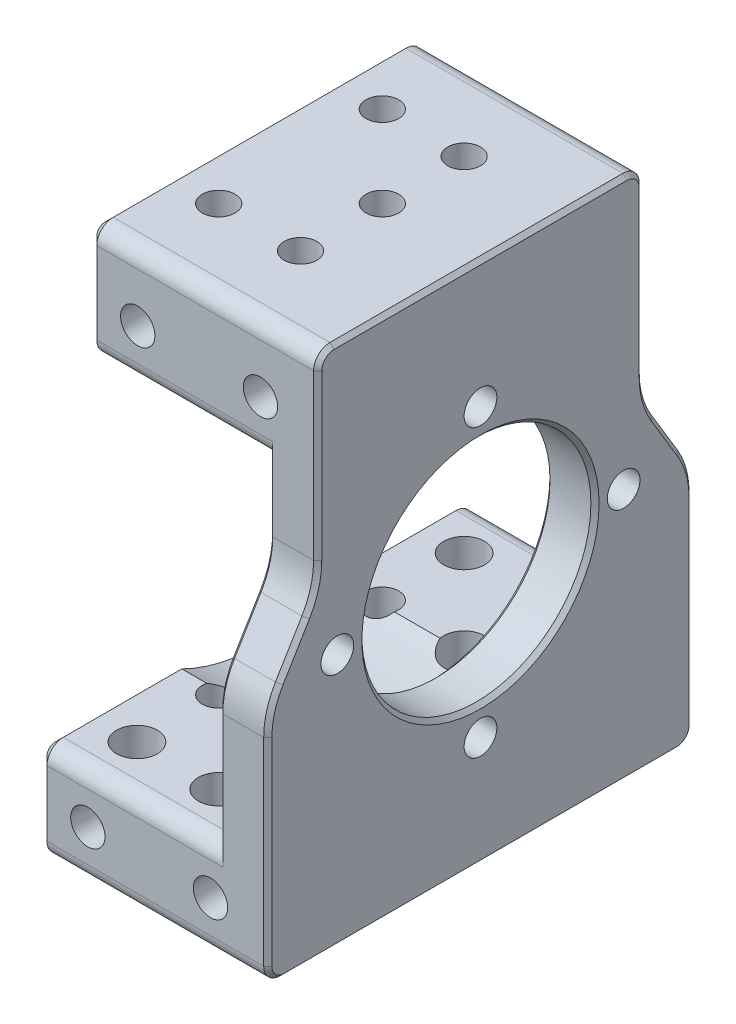
from build123d import *

# Parameters (mm, degrees)
SKETCH_1_W                     = 52
SKETCH_1_H                     = 64
EXTRUDE_1_DEPTH                = 28
SKETCH_2_W                     = 22
SKETCH_2_H                     = 52
CUT_EXTRUDE_1_DEPTH            = 78.900042429
SKETCH_3_W                     = 6.1
SKETCH_3_H                     = 35
CUT_EXTRUDE_2_DEPTH            = 81.215671716
SKETCH_4_W                     = 6.1
SKETCH_4_H                     = 35
CUT_EXTRUDE_3_DEPTH            = 81.215671716
SKETCH_5_W                     = 39.8
SKETCH_5_H                     = 14
EXTRUDE_2_DEPTH                = 22
CUT_EXTRUDE_4_DEPTH            = 22
CUT_EXTRUDE_5_DEPTH            = 22
DRAFT_1_ANGLE                  = 58.966808195
DRAFT_2_ANGLE                  = 58.966808195
HOLE_WIZARD_5_0_5_1_REACH      = 86.958
HOLE_WIZARD_5_0_5_1_BORE_R     = 2.5
HOLE_WIZARD_5_0_5_2_D          = 5
HOLE_WIZARD_5_0_5_2_DEPTH      = 12
HOLE_WIZARD_4_0_4_2_D          = 4
HOLE_WIZARD_4_0_4_3_D          = 4
HOLE_WIZARD_M24_1_D            = 28
HOLE_WIZARD_M24_1_DEPTH        = 28
HOLE_WIZARD_4_0_4_1_D          = 4
HOLE_WIZARD_4_2_4_2_1_D        = 4.2
HOLE_WIZARD_5_0_5_3_D          = 5
HOLE_WIZARD_5_0_5_3_DEPTH      = 12
HOLE_WIZARD_4_2_4_2_2_D        = 4.2
SKETCH_26_W                    = 2.5
SKETCH_26_H                    = 9.814155669
SKETCH_28_W                    = 2
SKETCH_28_H                    = 85.3
HOLE_WIZARD_4_0_4_4_AT_2_COUNT = 2
HOLE_WIZARD_4_0_4_4_AT_2_PITCH = 20
HOLE_WIZARD_5_0_5_6_D          = 5
HOLE_WIZARD_5_0_5_6_DEPTH      = 16.7
HOLE_WIZARD_4_2_4_2_3_D        = 4.2
HOLE_WIZARD_4_2_4_2_3_DEPTH    = 45.9
FILLET_1_R                     = 2
FILLET_2_R                     = 10
CHAMFER_1_SIZE                 = 0.5
CHAMFER_2_SIZE                 = 1
SKETCH_34_R                    = 2.5
CUT_EXTRUDE_6_DEPTH            = 10


with BuildPart() as part:
    # 草图1 → 凸台-拉伸1 (new body)
    with BuildSketch(Plane(origin=(7.558311674, 0, 0), x_dir=(0, 0, -1), z_dir=(1, 0, 0))):
        with Locations((-26, 22.282170082)):
            Rectangle(SKETCH_1_W, SKETCH_1_H)
    extrude(amount=-EXTRUDE_1_DEPTH)

    # 草图2 → 切除-拉伸1 (cut, through all)
    with BuildSketch(Plane(origin=(0, 0, 0), x_dir=(-1, 0, 0), z_dir=(0, 0, -1))):
        with Locations((9.441688326, 28.282170082)):
            Rectangle(SKETCH_2_W, SKETCH_2_H)
    extrude(amount=-CUT_EXTRUDE_1_DEPTH, mode=Mode.SUBTRACT)

    # 草图3 → 切除-拉伸2 (cut, through all)
    with BuildSketch(Plane(origin=(7.558311674, 0, 0), x_dir=(0, 0, -1), z_dir=(1, 0, 0))):
        with Locations((-48.95, 36.782170082)):
            Rectangle(SKETCH_3_W, SKETCH_3_H)
    extrude(amount=-CUT_EXTRUDE_2_DEPTH, mode=Mode.SUBTRACT)

    # 草图4 → 切除-拉伸3 (cut, through all)
    with BuildSketch(Plane(origin=(7.558311674, 0, 0), x_dir=(0, 0, -1), z_dir=(1, 0, 0))):
        with Locations((-3.05, 36.782170082)):
            Rectangle(SKETCH_4_W, SKETCH_4_H)
    extrude(amount=-CUT_EXTRUDE_3_DEPTH, mode=Mode.SUBTRACT)

    # 草图5 → 凸台-拉伸2 (add)
    with BuildSketch(Plane.ZY.offset(-1.558311674)):
        with Locations((26, 47.282170082)):
            Rectangle(SKETCH_5_W, SKETCH_5_H)
    extrude(amount=EXTRUDE_2_DEPTH)

    # 草图6 → 切除-拉伸4 (cut)
    with BuildSketch(Plane.ZY.offset(20.441688326)):
        with BuildLine():
            Line((16.483566845, 40.282170082), (35.516433155, 40.282170082))
            ThreePointArc((35.516433155, 40.282170082), (26, 42.532170082), (16.483566845, 40.282170082))
        make_face()
    extrude(amount=-CUT_EXTRUDE_4_DEPTH, mode=Mode.SUBTRACT)

    # 草图7 → 切除-拉伸5 (cut)
    with BuildSketch(Plane.ZY.offset(20.441688326)):
        with BuildLine():
            Line((35.516433155, 2.282170082), (16.483566845, 2.282170082))
            ThreePointArc((16.483566845, 2.282170082), (26, 0.032170082), (35.516433155, 2.282170082))
        make_face()
    extrude(amount=-CUT_EXTRUDE_5_DEPTH, mode=Mode.SUBTRACT)

    # 拔模1
    draft_1_faces = [part.faces().sort_by_distance(p)[0] for p in [
        (4.558311674, 19.282170082, 48.95),
    ]]
    draft(draft_1_faces, Plane(origin=(-20.441688326, 54.282170082, 52), x_dir=(1, 0, 0), z_dir=(0, 0, 1)), DRAFT_1_ANGLE)

    # 拔模2
    draft_2_faces = [part.faces().sort_by_distance(p)[0] for p in [
        (4.558311674, 19.282170082, 3.05),
    ]]
    draft(draft_2_faces, Plane(origin=(-20.441688326, -9.717829918, 0), x_dir=(-1, 0, 0), z_dir=(0, 0, -1)), DRAFT_2_ANGLE)

    # Ø5.0 (5) 直径孔1 bore → Ø5.0 (5) 直径孔1 (cut, up to next)
    with BuildSketch(Plane(origin=(0, -9.717829918, 0), x_dir=(-1, 0, 0), z_dir=(0, -1, 0)), mode=Mode.PRIVATE) as hole_wizard_5_0_5_1_sk1:
        with Locations((4.441688326, -26)):
            Circle(HOLE_WIZARD_5_0_5_1_BORE_R)
    hole_wizard_5_0_5_1_tool1 = extrude(hole_wizard_5_0_5_1_sk1.sketch, amount=-HOLE_WIZARD_5_0_5_1_REACH, mode=Mode.PRIVATE) & part.part
    add(hole_wizard_5_0_5_1_tool1.solids().sort_by_distance((-4.441688, -9.71783, 26))[0], mode=Mode.SUBTRACT)

    # Ø5.0 (5) 直径孔2
    with Locations(Plane(origin=(0, -9.717829918, 0), x_dir=(-1, 0, 0), z_dir=(0, -1, 0))):
        with Locations((4.441688326, -36), (4.441688326, -16)):
            Hole(HOLE_WIZARD_5_0_5_2_D / 2, depth=HOLE_WIZARD_5_0_5_2_DEPTH)

    # Ø4.0 (4) 直径孔2 (through all)
    with Locations(Plane(origin=(0, 54.282170082, 0), x_dir=(1, 0, 0), z_dir=(0, 1, 0))):
        with Locations((-4.441688326, -26)):
            Hole(HOLE_WIZARD_4_0_4_2_D / 2)

    # Ø4.0 (4) 直径孔3 (through all)
    with Locations(Plane(origin=(0, 54.282170082, 0), x_dir=(1, 0, 0), z_dir=(0, 1, 0))):
        with Locations((-4.441688326, -36), (-4.441688326, -16)):
            Hole(HOLE_WIZARD_4_0_4_3_D / 2)

    # M24 间隙孔1
    with Locations(Plane(origin=(7.558311674, 0, 0), x_dir=(0, 0, -1), z_dir=(1, 0, 0))):
        with Locations((-26, 21.282170082)):
            Hole(HOLE_WIZARD_M24_1_D / 2, depth=HOLE_WIZARD_M24_1_DEPTH)

    # Ø4.0 (4) 直径孔1 (through all)
    with Locations(Plane.ZY.offset(-1.558311674)):
        with Locations((43.5, 21.282170082), (8.5, 21.282170082), (26, 3.782170082), (26, 38.782170082)):
            Hole(HOLE_WIZARD_4_0_4_1_D / 2)

    # Ø4.2 (4.2) 直径孔1 (through all)
    with Locations(Plane.XY.offset(52)):
        with Locations((0.558311674, -3.717829918)):
            Hole(HOLE_WIZARD_4_2_4_2_1_D / 2)

    # Ø5.0 (5) 直径孔3
    with Locations(Plane(origin=(0, 2.282170082, 0), x_dir=(1, 0, 0), z_dir=(0, 1, 0))):
        with Locations((-4.441688326, -46), (-4.441688326, -6)):
            Hole(HOLE_WIZARD_5_0_5_3_D / 2, depth=HOLE_WIZARD_5_0_5_3_DEPTH)

    # Ø4.2 (4.2) 直径孔2 (through all)
    with Locations(Plane(origin=(0, 0, 0), x_dir=(-1, 0, 0), z_dir=(0, 0, -1))):
        with Locations((14.441688326, -3.717829918)):
            Hole(HOLE_WIZARD_4_2_4_2_2_D / 2)

    # 草图26 → Ø5.0 (5) 直径孔4 (revolve, cut)
    with BuildSketch(Plane(origin=(-14.441688326, 0.096325751, 26), x_dir=(0, 0, 1), z_dir=(1, 0, 0))):
        with Locations((1.25, 4.907077834)):
            Rectangle(SKETCH_26_W, SKETCH_26_H)
    revolve(axis=Axis((-14.441688326, 6.446325751, 26), (0, -1, 0)), mode=Mode.SUBTRACT)

    # 草图28 → Ø4.0 (4) 直径孔4 (revolve, cut)
    with BuildSketch(Plane(origin=(-14.441688326, -2.418791804, 36), x_dir=(0, 0, -1), z_dir=(1, 0, 0))):
        with Locations((1, 42.65)):
            Rectangle(SKETCH_28_W, SKETCH_28_H)
    hole_wizard_4_0_4_4 = revolve(axis=Axis((-14.441688326, -8.768791804, 36), (0, 1, 0)), mode=Mode.SUBTRACT)

    # Ø4.0 (4) 直径孔4 at 2: Ø4.0 (4) 直径孔4 ×2
    with Locations(*[(0, 0, -i * HOLE_WIZARD_4_0_4_4_AT_2_PITCH) for i in range(1, HOLE_WIZARD_4_0_4_4_AT_2_COUNT)]):
        add(hole_wizard_4_0_4_4, mode=Mode.SUBTRACT)

    # Ø5.0 (5) 直径孔6
    with Locations(Plane(origin=(0, 2.282170082, 0), x_dir=(1, 0, 0), z_dir=(0, 1, 0))):
        with Locations((-14.441688326, -46), (-14.441688326, -6)):
            Hole(HOLE_WIZARD_5_0_5_6_D / 2, depth=HOLE_WIZARD_5_0_5_6_DEPTH)

    # Ø4.2 (4.2) 直径孔3
    with Locations(Plane(origin=(0, 0, 6.1), x_dir=(-1, 0, 0), z_dir=(0, 0, -1))):
        with Locations((14.441688326, 46.282170082), (-0.558311674, 46.282170082)):
            Hole(HOLE_WIZARD_4_2_4_2_3_D / 2, depth=HOLE_WIZARD_4_2_4_2_3_DEPTH)

    # 圆角1
    fillet_1_edges = [part.edges().sort_by_distance(p)[0] for p in [
        (-9.441688326, 2.282170082, 52),
        (-9.441688326, 2.282170082, 0),
        (-6.441688326, 54.282170082, 45.9),
        (-6.441688326, 54.282170082, 6.1),
        (-9.441688326, 40.282170082, 6.1),
        (-9.441688326, 40.282170082, 45.9),
        (-6.441688326, -9.717829918, 0),
        (-6.441688326, -9.717829918, 52),
    ]]
    fillet(fillet_1_edges, radius=FILLET_1_R)

    # 圆角2
    fillet_2_edges = [part.edges().sort_by_distance(p)[0] for p in [
        (4.558311674, 19.282170082, 52),
        (4.558311674, 29.420966061, 45.9),
        (4.558311674, 19.282170082, 0),
        (4.558311674, 29.420966061, 6.1),
    ]]
    fillet(fillet_2_edges, radius=FILLET_2_R)

    # 倒角1
    chamfer_1_edges = [part.edges().sort_by_distance(p)[0] for p in [
        (1.558311674, 21.282170082, 12),
        (7.558311674, 21.282170082, 12),
        (7.558311674, 42.239750567, 6.1),
        (7.558311674, 54.282170082, 26),
        (7.558311674, -9.717829918, 26),
        (7.558311674, 4.393987586, 0),
        (7.558311674, 53.696383644, 45.314213562),
        (7.558311674, -9.132043481, 51.414213562),
        (7.558311674, -9.132043481, 0.585786438),
        (7.558311674, 53.696383644, 6.685786438),
        (1.558311674, 8.393987586, 0),
        (7.558311674, 42.239750567, 45.9),
        (7.558311674, 24.351568072, 48.95),
        (7.558311674, 4.393987586, 52),
        (7.558311674, 24.351568072, 3.05),
        (7.558311674, 19.180979924, 51.635530063),
        (7.558311674, 19.180979924, 0.364469937),
        (1.558311674, 24.351568072, 3.05),
        (1.558311674, 8.393987586, 52),
        (1.558311674, 24.351568072, 48.95),
        (1.558311674, 37.239750567, 45.9),
        (1.558311674, 19.180979924, 51.635530063),
        (1.558311674, 19.180979924, 0.364469937),
        (7.558311674, 29.522156219, 46.264469937),
        (1.558311674, 29.522156219, 46.264469937),
        (7.558311674, 29.522156219, 5.735530063),
        (1.558311674, 29.522156219, 5.735530063),
        (1.558311674, 37.239750567, 6.1),
    ]]
    chamfer(chamfer_1_edges, length=CHAMFER_1_SIZE)

    # 倒角2
    chamfer_2_edges = [part.edges().sort_by_distance(p)[0] for p in [
        (-20.441688326, 47.282170082, 6.1),
        (-20.441688326, 54.282170082, 26),
        (-20.441688326, 40.282170082, 12.291783422),
        (-20.441688326, 47.282170082, 45.9),
        (-20.441688326, 53.696383644, 45.314213562),
        (-20.441688326, 40.867956519, 45.314213562),
        (-20.441688326, 40.867956519, 6.685786438),
        (-20.441688326, 53.696383644, 6.685786438),
        (-20.441688326, -9.717829918, 26),
        (-20.441688326, -3.717829918, 0),
        (-20.441688326, 2.282170082, 42.758216578),
        (-20.441688326, -3.717829918, 52),
        (-20.441688326, 1.696383644, 51.414213562),
        (-20.441688326, 1.696383644, 0.585786438),
        (-20.441688326, -9.132043481, 51.414213562),
        (-20.441688326, -9.132043481, 0.585786438),
        (-20.441688326, 40.282170082, 39.708216578),
        (-20.441688326, 42.532170082, 26),
        (-20.441688326, 2.282170082, 9.241783422),
        (-20.441688326, 0.032170082, 26),
    ]]
    chamfer(chamfer_2_edges, length=CHAMFER_2_SIZE)

    # 草图34 → 切除-拉伸6 (cut)
    with BuildSketch(Plane.XZ.offset(9.717829918)):
        with Locations(Location((-14.441688326, 26, 0), (0, 0, 90))):
            Circle(SKETCH_34_R)
    extrude(amount=-CUT_EXTRUDE_6_DEPTH, mode=Mode.SUBTRACT)


solid = part.part
